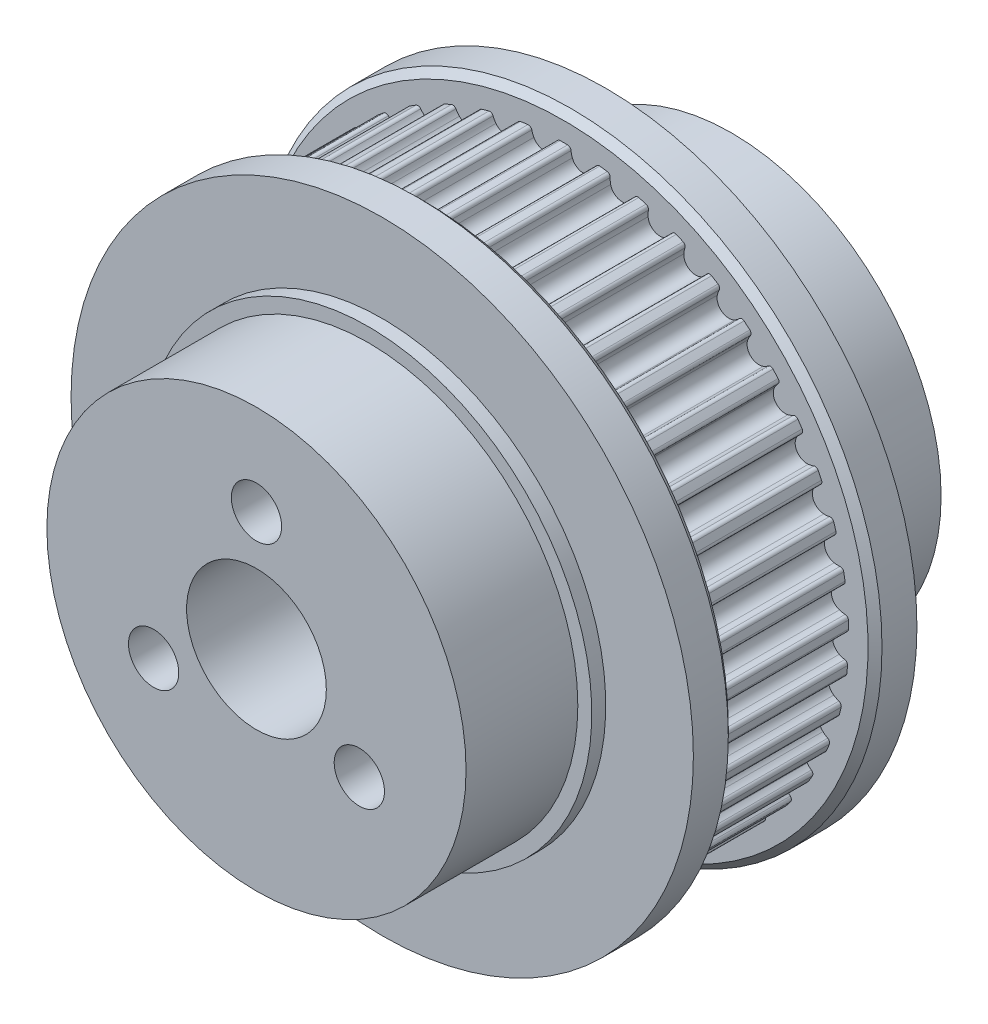
from build123d import *

# Parameters (mm, degrees)
SKETCH_1_R                       = 20.769720073
EXTRUDE_1_DEPTH                  = 5
CUT_EXTRUDE_1_DEPTH              = 32.028415104
PATTERN_CIRCULAR_1_COUNT         = 45
PATTERN_CIRCULAR_1_COPY_1_DEPTH  = 32.028415104
PATTERN_CIRCULAR_1_COPY_2_DEPTH  = 32.028415104
PATTERN_CIRCULAR_1_COPY_3_DEPTH  = 32.028415104
PATTERN_CIRCULAR_1_COPY_4_DEPTH  = 32.028415104
PATTERN_CIRCULAR_1_COPY_5_DEPTH  = 32.028415104
PATTERN_CIRCULAR_1_COPY_6_DEPTH  = 32.028415104
PATTERN_CIRCULAR_1_COPY_7_DEPTH  = 32.028415104
PATTERN_CIRCULAR_1_COPY_8_DEPTH  = 32.028415104
PATTERN_CIRCULAR_1_COPY_9_DEPTH  = 32.028415104
PATTERN_CIRCULAR_1_COPY_10_DEPTH = 32.028415104
PATTERN_CIRCULAR_1_COPY_11_DEPTH = 32.028415104
PATTERN_CIRCULAR_1_COPY_12_DEPTH = 32.028415104
PATTERN_CIRCULAR_1_COPY_13_DEPTH = 32.028415104
PATTERN_CIRCULAR_1_COPY_14_DEPTH = 32.028415104
PATTERN_CIRCULAR_1_COPY_15_DEPTH = 32.028415104
PATTERN_CIRCULAR_1_COPY_16_DEPTH = 32.028415104
PATTERN_CIRCULAR_1_COPY_17_DEPTH = 32.028415104
PATTERN_CIRCULAR_1_COPY_18_DEPTH = 32.028415104
PATTERN_CIRCULAR_1_COPY_19_DEPTH = 32.028415104
PATTERN_CIRCULAR_1_COPY_20_DEPTH = 32.028415104
PATTERN_CIRCULAR_1_COPY_21_DEPTH = 32.028415104
PATTERN_CIRCULAR_1_COPY_22_DEPTH = 32.028415104
PATTERN_CIRCULAR_1_COPY_23_DEPTH = 32.028415104
PATTERN_CIRCULAR_1_COPY_24_DEPTH = 32.028415104
PATTERN_CIRCULAR_1_COPY_25_DEPTH = 32.028415104
PATTERN_CIRCULAR_1_COPY_26_DEPTH = 32.028415104
PATTERN_CIRCULAR_1_COPY_27_DEPTH = 32.028415104
PATTERN_CIRCULAR_1_COPY_28_DEPTH = 32.028415104
PATTERN_CIRCULAR_1_COPY_29_DEPTH = 32.028415104
PATTERN_CIRCULAR_1_COPY_30_DEPTH = 32.028415104
PATTERN_CIRCULAR_1_COPY_31_DEPTH = 32.028415104
PATTERN_CIRCULAR_1_COPY_32_DEPTH = 32.028415104
PATTERN_CIRCULAR_1_COPY_33_DEPTH = 32.028415104
PATTERN_CIRCULAR_1_COPY_34_DEPTH = 32.028415104
PATTERN_CIRCULAR_1_COPY_35_DEPTH = 32.028415104
PATTERN_CIRCULAR_1_COPY_36_DEPTH = 32.028415104
PATTERN_CIRCULAR_1_COPY_37_DEPTH = 32.028415104
PATTERN_CIRCULAR_1_COPY_38_DEPTH = 32.028415104
PATTERN_CIRCULAR_1_COPY_39_DEPTH = 32.028415104
PATTERN_CIRCULAR_1_COPY_40_DEPTH = 32.028415104
PATTERN_CIRCULAR_1_COPY_41_DEPTH = 32.028415104
PATTERN_CIRCULAR_1_COPY_42_DEPTH = 32.028415104
PATTERN_CIRCULAR_1_COPY_43_DEPTH = 32.028415104
PATTERN_CIRCULAR_1_COPY_44_DEPTH = 32.028415104
SKETCH_3_R                       = 22.269720073
EXTRUDE_2_DEPTH                  = 3
CHAMFER_1_SIZE                   = 0.5
SKETCH_7_R                       = 22.269720073
EXTRUDE_3_DEPTH                  = 3
CHAMFER_2_SIZE                   = 0.5
SKETCH_12_R                      = 15
EXTRUDE_4_DEPTH                  = 9
SKETCH_16_R                      = 16
SKETCH_16_R_2                    = 15
EXTRUDE_7_DEPTH                  = 1
SKETCH_4_R                       = 5
CUT_EXTRUDE_4_DEPTH              = 36.789395976
CUT_EXTRUDE_4_DEPTH_BACK         = 36.789395976
HOLE_WIZARD_M3_1_D               = 3.6
HOLE_WIZARD_M3_1_CBORE_D         = 6.5
HOLE_WIZARD_M3_1_CBORE_DEPTH     = 13
PATTERN_CIRCULAR_2_COUNT         = 3


with BuildPart() as part:
    # ｽｹｯﾁ1 → ﾎﾞｽ - 押し出し1 (new, symmetric)
    with BuildSketch(Plane.XY):
        Circle(SKETCH_1_R)
    extrude(amount=EXTRUDE_1_DEPTH, both=True)

    # ｽｹｯﾁ2 → ｶｯﾄ - 押し出し1 (cut, through all)
    with BuildSketch(Plane.XY.offset(5)):
        with BuildLine():
            Line((0, 20.769720073), (0, 20.388720073))
            ThreePointArc((0, 20.388720073), (0.134629216, 20.388275582), (0.269252561, 20.386942127))
            ThreePointArc((0.269252561, 20.386942127), (0.436454679, 20.319798607), (0.515090947, 20.157684024))
            ThreePointArc((0.515090947, 20.157684024), (0.546429865, 19.952254747), (0.605495363, 19.753019753))
            ThreePointArc((0.605495363, 19.753019753), (0.89304001, 19.368993677), (1.342722836, 19.201831159))
            Line((1.342722836, 19.201831159), (1.448822433, 20.719126079))
            ThreePointArc((1.448822433, 20.719126079), (0.724852777, 20.757067721), (0, 20.769720073))
        make_face()
    cut_extrude_1 = extrude(amount=-CUT_EXTRUDE_1_DEPTH, mode=Mode.SUBTRACT)

    # ﾐﾗｰ1: ｶｯﾄ - 押し出し1 across plane
    add(cut_extrude_1.mirror(Plane(origin=(0, 0, 0), x_dir=(0, 0, 1), z_dir=(1, 0, 0))), mode=Mode.SUBTRACT)

    # 円形ﾊﾟﾀｰﾝ1: ｶｯﾄ - 押し出し1 ×45 about axis
    pattern_circular_1_axis = Axis((0, 0, 0), (0, 0, 1))
    for i in range(1, PATTERN_CIRCULAR_1_COUNT):
        add(cut_extrude_1.rotate(pattern_circular_1_axis, i * 360 / PATTERN_CIRCULAR_1_COUNT), mode=Mode.SUBTRACT)

    # 円形ﾊﾟﾀｰﾝ1 copy 1 sketch → 円形ﾊﾟﾀｰﾝ1 copy 1 (cut, through all)
    with BuildSketch(Plane(origin=(0, 0, 5), x_dir=(-0.9902680687415704, -0.13917310096006544, 0), z_dir=(0, 0, 1))):
        with BuildLine():
            Line((0, -20.769720073), (0, -20.388720073))
            ThreePointArc((0, -20.388720073), (0.134629216, -20.388275582), (0.269252561, -20.386942127))
            ThreePointArc((0.269252561, -20.386942127), (0.436454679, -20.319798607), (0.515090947, -20.157684024))
            ThreePointArc((0.515090947, -20.157684024), (0.546429865, -19.952254747), (0.605495363, -19.753019753))
            ThreePointArc((0.605495363, -19.753019753), (0.89304001, -19.368993677), (1.342722836, -19.201831159))
            Line((1.342722836, -19.201831159), (1.448822433, -20.719126079))
            ThreePointArc((1.448822433, -20.719126079), (0.724852777, -20.757067721), (0, -20.769720073))
        make_face()
    extrude(amount=-PATTERN_CIRCULAR_1_COPY_1_DEPTH, mode=Mode.SUBTRACT)

    # 円形ﾊﾟﾀｰﾝ1 copy 2 sketch → 円形ﾊﾟﾀｰﾝ1 copy 2 (cut, through all)
    with BuildSketch(Plane(origin=(0, 0, 5), x_dir=(-0.9612616959383189, -0.27563735581699916, 0), z_dir=(0, 0, 1))):
        with BuildLine():
            Line((0, -20.769720073), (0, -20.388720073))
            ThreePointArc((0, -20.388720073), (0.134629216, -20.388275582), (0.269252561, -20.386942127))
            ThreePointArc((0.269252561, -20.386942127), (0.436454679, -20.319798607), (0.515090947, -20.157684024))
            ThreePointArc((0.515090947, -20.157684024), (0.546429865, -19.952254747), (0.605495363, -19.753019753))
            ThreePointArc((0.605495363, -19.753019753), (0.89304001, -19.368993677), (1.342722836, -19.201831159))
            Line((1.342722836, -19.201831159), (1.448822433, -20.719126079))
            ThreePointArc((1.448822433, -20.719126079), (0.724852777, -20.757067721), (0, -20.769720073))
        make_face()
    extrude(amount=-PATTERN_CIRCULAR_1_COPY_2_DEPTH, mode=Mode.SUBTRACT)

    # 円形ﾊﾟﾀｰﾝ1 copy 3 sketch → 円形ﾊﾟﾀｰﾝ1 copy 3 (cut, through all)
    with BuildSketch(Plane(origin=(0, 0, 5), x_dir=(-0.9135454576426009, -0.4067366430758002, 0), z_dir=(0, 0, 1))):
        with BuildLine():
            Line((0, -20.769720073), (0, -20.388720073))
            ThreePointArc((0, -20.388720073), (0.134629216, -20.388275582), (0.269252561, -20.386942127))
            ThreePointArc((0.269252561, -20.386942127), (0.436454679, -20.319798607), (0.515090947, -20.157684024))
            ThreePointArc((0.515090947, -20.157684024), (0.546429865, -19.952254747), (0.605495363, -19.753019753))
            ThreePointArc((0.605495363, -19.753019753), (0.89304001, -19.368993677), (1.342722836, -19.201831159))
            Line((1.342722836, -19.201831159), (1.448822433, -20.719126079))
            ThreePointArc((1.448822433, -20.719126079), (0.724852777, -20.757067721), (0, -20.769720073))
        make_face()
    extrude(amount=-PATTERN_CIRCULAR_1_COPY_3_DEPTH, mode=Mode.SUBTRACT)

    # 円形ﾊﾟﾀｰﾝ1 copy 4 sketch → 円形ﾊﾟﾀｰﾝ1 copy 4 (cut, through all)
    with BuildSketch(Plane(origin=(0, 0, 5), x_dir=(-0.848048096156426, -0.5299192642332049, 0), z_dir=(0, 0, 1))):
        with BuildLine():
            Line((0, -20.769720073), (0, -20.388720073))
            ThreePointArc((0, -20.388720073), (0.134629216, -20.388275582), (0.269252561, -20.386942127))
            ThreePointArc((0.269252561, -20.386942127), (0.436454679, -20.319798607), (0.515090947, -20.157684024))
            ThreePointArc((0.515090947, -20.157684024), (0.546429865, -19.952254747), (0.605495363, -19.753019753))
            ThreePointArc((0.605495363, -19.753019753), (0.89304001, -19.368993677), (1.342722836, -19.201831159))
            Line((1.342722836, -19.201831159), (1.448822433, -20.719126079))
            ThreePointArc((1.448822433, -20.719126079), (0.724852777, -20.757067721), (0, -20.769720073))
        make_face()
    extrude(amount=-PATTERN_CIRCULAR_1_COPY_4_DEPTH, mode=Mode.SUBTRACT)

    # 円形ﾊﾟﾀｰﾝ1 copy 5 sketch → 円形ﾊﾟﾀｰﾝ1 copy 5 (cut, through all)
    with BuildSketch(Plane(origin=(0, 0, 5), x_dir=(-0.766044443118978, -0.6427876096865393, 0), z_dir=(0, 0, 1))):
        with BuildLine():
            Line((0, -20.769720073), (0, -20.388720073))
            ThreePointArc((0, -20.388720073), (0.134629216, -20.388275582), (0.269252561, -20.386942127))
            ThreePointArc((0.269252561, -20.386942127), (0.436454679, -20.319798607), (0.515090947, -20.157684024))
            ThreePointArc((0.515090947, -20.157684024), (0.546429865, -19.952254747), (0.605495363, -19.753019753))
            ThreePointArc((0.605495363, -19.753019753), (0.89304001, -19.368993677), (1.342722836, -19.201831159))
            Line((1.342722836, -19.201831159), (1.448822433, -20.719126079))
            ThreePointArc((1.448822433, -20.719126079), (0.724852777, -20.757067721), (0, -20.769720073))
        make_face()
    extrude(amount=-PATTERN_CIRCULAR_1_COPY_5_DEPTH, mode=Mode.SUBTRACT)

    # 円形ﾊﾟﾀｰﾝ1 copy 6 sketch → 円形ﾊﾟﾀｰﾝ1 copy 6 (cut, through all)
    with BuildSketch(Plane(origin=(0, 0, 5), x_dir=(-0.6691306063588582, -0.7431448254773942, 0), z_dir=(0, 0, 1))):
        with BuildLine():
            Line((0, -20.769720073), (0, -20.388720073))
            ThreePointArc((0, -20.388720073), (0.134629216, -20.388275582), (0.269252561, -20.386942127))
            ThreePointArc((0.269252561, -20.386942127), (0.436454679, -20.319798607), (0.515090947, -20.157684024))
            ThreePointArc((0.515090947, -20.157684024), (0.546429865, -19.952254747), (0.605495363, -19.753019753))
            ThreePointArc((0.605495363, -19.753019753), (0.89304001, -19.368993677), (1.342722836, -19.201831159))
            Line((1.342722836, -19.201831159), (1.448822433, -20.719126079))
            ThreePointArc((1.448822433, -20.719126079), (0.724852777, -20.757067721), (0, -20.769720073))
        make_face()
    extrude(amount=-PATTERN_CIRCULAR_1_COPY_6_DEPTH, mode=Mode.SUBTRACT)

    # 円形ﾊﾟﾀｰﾝ1 copy 7 sketch → 円形ﾊﾟﾀｰﾝ1 copy 7 (cut, through all)
    with BuildSketch(Plane(origin=(0, 0, 5), x_dir=(-0.5591929034707468, -0.8290375725550417, 0), z_dir=(0, 0, 1))):
        with BuildLine():
            Line((0, -20.769720073), (0, -20.388720073))
            ThreePointArc((0, -20.388720073), (0.134629216, -20.388275582), (0.269252561, -20.386942127))
            ThreePointArc((0.269252561, -20.386942127), (0.436454679, -20.319798607), (0.515090947, -20.157684024))
            ThreePointArc((0.515090947, -20.157684024), (0.546429865, -19.952254747), (0.605495363, -19.753019753))
            ThreePointArc((0.605495363, -19.753019753), (0.89304001, -19.368993677), (1.342722836, -19.201831159))
            Line((1.342722836, -19.201831159), (1.448822433, -20.719126079))
            ThreePointArc((1.448822433, -20.719126079), (0.724852777, -20.757067721), (0, -20.769720073))
        make_face()
    extrude(amount=-PATTERN_CIRCULAR_1_COPY_7_DEPTH, mode=Mode.SUBTRACT)

    # 円形ﾊﾟﾀｰﾝ1 copy 8 sketch → 円形ﾊﾟﾀｰﾝ1 copy 8 (cut, through all)
    with BuildSketch(Plane(origin=(0, 0, 5), x_dir=(-0.43837114678907746, -0.898794046299167, 0), z_dir=(0, 0, 1))):
        with BuildLine():
            Line((0, -20.769720073), (0, -20.388720073))
            ThreePointArc((0, -20.388720073), (0.134629216, -20.388275582), (0.269252561, -20.386942127))
            ThreePointArc((0.269252561, -20.386942127), (0.436454679, -20.319798607), (0.515090947, -20.157684024))
            ThreePointArc((0.515090947, -20.157684024), (0.546429865, -19.952254747), (0.605495363, -19.753019753))
            ThreePointArc((0.605495363, -19.753019753), (0.89304001, -19.368993677), (1.342722836, -19.201831159))
            Line((1.342722836, -19.201831159), (1.448822433, -20.719126079))
            ThreePointArc((1.448822433, -20.719126079), (0.724852777, -20.757067721), (0, -20.769720073))
        make_face()
    extrude(amount=-PATTERN_CIRCULAR_1_COPY_8_DEPTH, mode=Mode.SUBTRACT)

    # 円形ﾊﾟﾀｰﾝ1 copy 9 sketch → 円形ﾊﾟﾀｰﾝ1 copy 9 (cut, through all)
    with BuildSketch(Plane(origin=(0, 0, 5), x_dir=(-0.30901699437494745, -0.9510565162951535, 0), z_dir=(0, 0, 1))):
        with BuildLine():
            Line((0, -20.769720073), (0, -20.388720073))
            ThreePointArc((0, -20.388720073), (0.134629216, -20.388275582), (0.269252561, -20.386942127))
            ThreePointArc((0.269252561, -20.386942127), (0.436454679, -20.319798607), (0.515090947, -20.157684024))
            ThreePointArc((0.515090947, -20.157684024), (0.546429865, -19.952254747), (0.605495363, -19.753019753))
            ThreePointArc((0.605495363, -19.753019753), (0.89304001, -19.368993677), (1.342722836, -19.201831159))
            Line((1.342722836, -19.201831159), (1.448822433, -20.719126079))
            ThreePointArc((1.448822433, -20.719126079), (0.724852777, -20.757067721), (0, -20.769720073))
        make_face()
    extrude(amount=-PATTERN_CIRCULAR_1_COPY_9_DEPTH, mode=Mode.SUBTRACT)

    # 円形ﾊﾟﾀｰﾝ1 copy 10 sketch → 円形ﾊﾟﾀｰﾝ1 copy 10 (cut, through all)
    with BuildSketch(Plane(origin=(0, 0, 5), x_dir=(-0.17364817766693041, -0.984807753012208, 0), z_dir=(0, 0, 1))):
        with BuildLine():
            Line((0, -20.769720073), (0, -20.388720073))
            ThreePointArc((0, -20.388720073), (0.134629216, -20.388275582), (0.269252561, -20.386942127))
            ThreePointArc((0.269252561, -20.386942127), (0.436454679, -20.319798607), (0.515090947, -20.157684024))
            ThreePointArc((0.515090947, -20.157684024), (0.546429865, -19.952254747), (0.605495363, -19.753019753))
            ThreePointArc((0.605495363, -19.753019753), (0.89304001, -19.368993677), (1.342722836, -19.201831159))
            Line((1.342722836, -19.201831159), (1.448822433, -20.719126079))
            ThreePointArc((1.448822433, -20.719126079), (0.724852777, -20.757067721), (0, -20.769720073))
        make_face()
    extrude(amount=-PATTERN_CIRCULAR_1_COPY_10_DEPTH, mode=Mode.SUBTRACT)

    # 円形ﾊﾟﾀｰﾝ1 copy 11 sketch → 円形ﾊﾟﾀｰﾝ1 copy 11 (cut, through all)
    with BuildSketch(Plane(origin=(0, 0, 5), x_dir=(-0.03489949670250108, -0.9993908270190958, 0), z_dir=(0, 0, 1))):
        with BuildLine():
            Line((0, -20.769720073), (0, -20.388720073))
            ThreePointArc((0, -20.388720073), (0.134629216, -20.388275582), (0.269252561, -20.386942127))
            ThreePointArc((0.269252561, -20.386942127), (0.436454679, -20.319798607), (0.515090947, -20.157684024))
            ThreePointArc((0.515090947, -20.157684024), (0.546429865, -19.952254747), (0.605495363, -19.753019753))
            ThreePointArc((0.605495363, -19.753019753), (0.89304001, -19.368993677), (1.342722836, -19.201831159))
            Line((1.342722836, -19.201831159), (1.448822433, -20.719126079))
            ThreePointArc((1.448822433, -20.719126079), (0.724852777, -20.757067721), (0, -20.769720073))
        make_face()
    extrude(amount=-PATTERN_CIRCULAR_1_COPY_11_DEPTH, mode=Mode.SUBTRACT)

    # 円形ﾊﾟﾀｰﾝ1 copy 12 sketch → 円形ﾊﾟﾀｰﾝ1 copy 12 (cut, through all)
    with BuildSketch(Plane(origin=(0, 0, 5), x_dir=(0.10452846326765355, -0.9945218953682733, 0), z_dir=(0, 0, 1))):
        with BuildLine():
            Line((0, -20.769720073), (0, -20.388720073))
            ThreePointArc((0, -20.388720073), (0.134629216, -20.388275582), (0.269252561, -20.386942127))
            ThreePointArc((0.269252561, -20.386942127), (0.436454679, -20.319798607), (0.515090947, -20.157684024))
            ThreePointArc((0.515090947, -20.157684024), (0.546429865, -19.952254747), (0.605495363, -19.753019753))
            ThreePointArc((0.605495363, -19.753019753), (0.89304001, -19.368993677), (1.342722836, -19.201831159))
            Line((1.342722836, -19.201831159), (1.448822433, -20.719126079))
            ThreePointArc((1.448822433, -20.719126079), (0.724852777, -20.757067721), (0, -20.769720073))
        make_face()
    extrude(amount=-PATTERN_CIRCULAR_1_COPY_12_DEPTH, mode=Mode.SUBTRACT)

    # 円形ﾊﾟﾀｰﾝ1 copy 13 sketch → 円形ﾊﾟﾀｰﾝ1 copy 13 (cut, through all)
    with BuildSketch(Plane(origin=(0, 0, 5), x_dir=(0.24192189559966779, -0.9702957262759965, 0), z_dir=(0, 0, 1))):
        with BuildLine():
            Line((0, -20.769720073), (0, -20.388720073))
            ThreePointArc((0, -20.388720073), (0.134629216, -20.388275582), (0.269252561, -20.386942127))
            ThreePointArc((0.269252561, -20.386942127), (0.436454679, -20.319798607), (0.515090947, -20.157684024))
            ThreePointArc((0.515090947, -20.157684024), (0.546429865, -19.952254747), (0.605495363, -19.753019753))
            ThreePointArc((0.605495363, -19.753019753), (0.89304001, -19.368993677), (1.342722836, -19.201831159))
            Line((1.342722836, -19.201831159), (1.448822433, -20.719126079))
            ThreePointArc((1.448822433, -20.719126079), (0.724852777, -20.757067721), (0, -20.769720073))
        make_face()
    extrude(amount=-PATTERN_CIRCULAR_1_COPY_13_DEPTH, mode=Mode.SUBTRACT)

    # 円形ﾊﾟﾀｰﾝ1 copy 14 sketch → 円形ﾊﾟﾀｰﾝ1 copy 14 (cut, through all)
    with BuildSketch(Plane(origin=(0, 0, 5), x_dir=(0.37460659341591207, -0.9271838545667874, 0), z_dir=(0, 0, 1))):
        with BuildLine():
            Line((0, -20.769720073), (0, -20.388720073))
            ThreePointArc((0, -20.388720073), (0.134629216, -20.388275582), (0.269252561, -20.386942127))
            ThreePointArc((0.269252561, -20.386942127), (0.436454679, -20.319798607), (0.515090947, -20.157684024))
            ThreePointArc((0.515090947, -20.157684024), (0.546429865, -19.952254747), (0.605495363, -19.753019753))
            ThreePointArc((0.605495363, -19.753019753), (0.89304001, -19.368993677), (1.342722836, -19.201831159))
            Line((1.342722836, -19.201831159), (1.448822433, -20.719126079))
            ThreePointArc((1.448822433, -20.719126079), (0.724852777, -20.757067721), (0, -20.769720073))
        make_face()
    extrude(amount=-PATTERN_CIRCULAR_1_COPY_14_DEPTH, mode=Mode.SUBTRACT)

    # 円形ﾊﾟﾀｰﾝ1 copy 15 sketch → 円形ﾊﾟﾀｰﾝ1 copy 15 (cut, through all)
    with BuildSketch(Plane(origin=(0, 0, 5), x_dir=(0.4999999999999998, -0.8660254037844387, 0), z_dir=(0, 0, 1))):
        with BuildLine():
            Line((0, -20.769720073), (0, -20.388720073))
            ThreePointArc((0, -20.388720073), (0.134629216, -20.388275582), (0.269252561, -20.386942127))
            ThreePointArc((0.269252561, -20.386942127), (0.436454679, -20.319798607), (0.515090947, -20.157684024))
            ThreePointArc((0.515090947, -20.157684024), (0.546429865, -19.952254747), (0.605495363, -19.753019753))
            ThreePointArc((0.605495363, -19.753019753), (0.89304001, -19.368993677), (1.342722836, -19.201831159))
            Line((1.342722836, -19.201831159), (1.448822433, -20.719126079))
            ThreePointArc((1.448822433, -20.719126079), (0.724852777, -20.757067721), (0, -20.769720073))
        make_face()
    extrude(amount=-PATTERN_CIRCULAR_1_COPY_15_DEPTH, mode=Mode.SUBTRACT)

    # 円形ﾊﾟﾀｰﾝ1 copy 16 sketch → 円形ﾊﾟﾀｰﾝ1 copy 16 (cut, through all)
    with BuildSketch(Plane(origin=(0, 0, 5), x_dir=(0.6156614753256583, -0.788010753606722, 0), z_dir=(0, 0, 1))):
        with BuildLine():
            Line((0, -20.769720073), (0, -20.388720073))
            ThreePointArc((0, -20.388720073), (0.134629216, -20.388275582), (0.269252561, -20.386942127))
            ThreePointArc((0.269252561, -20.386942127), (0.436454679, -20.319798607), (0.515090947, -20.157684024))
            ThreePointArc((0.515090947, -20.157684024), (0.546429865, -19.952254747), (0.605495363, -19.753019753))
            ThreePointArc((0.605495363, -19.753019753), (0.89304001, -19.368993677), (1.342722836, -19.201831159))
            Line((1.342722836, -19.201831159), (1.448822433, -20.719126079))
            ThreePointArc((1.448822433, -20.719126079), (0.724852777, -20.757067721), (0, -20.769720073))
        make_face()
    extrude(amount=-PATTERN_CIRCULAR_1_COPY_16_DEPTH, mode=Mode.SUBTRACT)

    # 円形ﾊﾟﾀｰﾝ1 copy 17 sketch → 円形ﾊﾟﾀｰﾝ1 copy 17 (cut, through all)
    with BuildSketch(Plane(origin=(0, 0, 5), x_dir=(0.7193398003386512, -0.6946583704589971, 0), z_dir=(0, 0, 1))):
        with BuildLine():
            Line((0, -20.769720073), (0, -20.388720073))
            ThreePointArc((0, -20.388720073), (0.134629216, -20.388275582), (0.269252561, -20.386942127))
            ThreePointArc((0.269252561, -20.386942127), (0.436454679, -20.319798607), (0.515090947, -20.157684024))
            ThreePointArc((0.515090947, -20.157684024), (0.546429865, -19.952254747), (0.605495363, -19.753019753))
            ThreePointArc((0.605495363, -19.753019753), (0.89304001, -19.368993677), (1.342722836, -19.201831159))
            Line((1.342722836, -19.201831159), (1.448822433, -20.719126079))
            ThreePointArc((1.448822433, -20.719126079), (0.724852777, -20.757067721), (0, -20.769720073))
        make_face()
    extrude(amount=-PATTERN_CIRCULAR_1_COPY_17_DEPTH, mode=Mode.SUBTRACT)

    # 円形ﾊﾟﾀｰﾝ1 copy 18 sketch → 円形ﾊﾟﾀｰﾝ1 copy 18 (cut, through all)
    with BuildSketch(Plane(origin=(0, 0, 5), x_dir=(0.8090169943749473, -0.5877852522924732, 0), z_dir=(0, 0, 1))):
        with BuildLine():
            Line((0, -20.769720073), (0, -20.388720073))
            ThreePointArc((0, -20.388720073), (0.134629216, -20.388275582), (0.269252561, -20.386942127))
            ThreePointArc((0.269252561, -20.386942127), (0.436454679, -20.319798607), (0.515090947, -20.157684024))
            ThreePointArc((0.515090947, -20.157684024), (0.546429865, -19.952254747), (0.605495363, -19.753019753))
            ThreePointArc((0.605495363, -19.753019753), (0.89304001, -19.368993677), (1.342722836, -19.201831159))
            Line((1.342722836, -19.201831159), (1.448822433, -20.719126079))
            ThreePointArc((1.448822433, -20.719126079), (0.724852777, -20.757067721), (0, -20.769720073))
        make_face()
    extrude(amount=-PATTERN_CIRCULAR_1_COPY_18_DEPTH, mode=Mode.SUBTRACT)

    # 円形ﾊﾟﾀｰﾝ1 copy 19 sketch → 円形ﾊﾟﾀｰﾝ1 copy 19 (cut, through all)
    with BuildSketch(Plane(origin=(0, 0, 5), x_dir=(0.882947592858927, -0.4694715627858907, 0), z_dir=(0, 0, 1))):
        with BuildLine():
            Line((0, -20.769720073), (0, -20.388720073))
            ThreePointArc((0, -20.388720073), (0.134629216, -20.388275582), (0.269252561, -20.386942127))
            ThreePointArc((0.269252561, -20.386942127), (0.436454679, -20.319798607), (0.515090947, -20.157684024))
            ThreePointArc((0.515090947, -20.157684024), (0.546429865, -19.952254747), (0.605495363, -19.753019753))
            ThreePointArc((0.605495363, -19.753019753), (0.89304001, -19.368993677), (1.342722836, -19.201831159))
            Line((1.342722836, -19.201831159), (1.448822433, -20.719126079))
            ThreePointArc((1.448822433, -20.719126079), (0.724852777, -20.757067721), (0, -20.769720073))
        make_face()
    extrude(amount=-PATTERN_CIRCULAR_1_COPY_19_DEPTH, mode=Mode.SUBTRACT)

    # 円形ﾊﾟﾀｰﾝ1 copy 20 sketch → 円形ﾊﾟﾀｰﾝ1 copy 20 (cut, through all)
    with BuildSketch(Plane(origin=(0, 0, 5), x_dir=(0.9396926207859083, -0.3420201433256689, 0), z_dir=(0, 0, 1))):
        with BuildLine():
            Line((0, -20.769720073), (0, -20.388720073))
            ThreePointArc((0, -20.388720073), (0.134629216, -20.388275582), (0.269252561, -20.386942127))
            ThreePointArc((0.269252561, -20.386942127), (0.436454679, -20.319798607), (0.515090947, -20.157684024))
            ThreePointArc((0.515090947, -20.157684024), (0.546429865, -19.952254747), (0.605495363, -19.753019753))
            ThreePointArc((0.605495363, -19.753019753), (0.89304001, -19.368993677), (1.342722836, -19.201831159))
            Line((1.342722836, -19.201831159), (1.448822433, -20.719126079))
            ThreePointArc((1.448822433, -20.719126079), (0.724852777, -20.757067721), (0, -20.769720073))
        make_face()
    extrude(amount=-PATTERN_CIRCULAR_1_COPY_20_DEPTH, mode=Mode.SUBTRACT)

    # 円形ﾊﾟﾀｰﾝ1 copy 21 sketch → 円形ﾊﾟﾀｰﾝ1 copy 21 (cut, through all)
    with BuildSketch(Plane(origin=(0, 0, 5), x_dir=(0.9781476007338057, -0.20791169081775931, 0), z_dir=(0, 0, 1))):
        with BuildLine():
            Line((0, -20.769720073), (0, -20.388720073))
            ThreePointArc((0, -20.388720073), (0.134629216, -20.388275582), (0.269252561, -20.386942127))
            ThreePointArc((0.269252561, -20.386942127), (0.436454679, -20.319798607), (0.515090947, -20.157684024))
            ThreePointArc((0.515090947, -20.157684024), (0.546429865, -19.952254747), (0.605495363, -19.753019753))
            ThreePointArc((0.605495363, -19.753019753), (0.89304001, -19.368993677), (1.342722836, -19.201831159))
            Line((1.342722836, -19.201831159), (1.448822433, -20.719126079))
            ThreePointArc((1.448822433, -20.719126079), (0.724852777, -20.757067721), (0, -20.769720073))
        make_face()
    extrude(amount=-PATTERN_CIRCULAR_1_COPY_21_DEPTH, mode=Mode.SUBTRACT)

    # 円形ﾊﾟﾀｰﾝ1 copy 22 sketch → 円形ﾊﾟﾀｰﾝ1 copy 22 (cut, through all)
    with BuildSketch(Plane(origin=(0, 0, 5), x_dir=(0.9975640502598242, -0.06975647374412552, 0), z_dir=(0, 0, 1))):
        with BuildLine():
            Line((0, -20.769720073), (0, -20.388720073))
            ThreePointArc((0, -20.388720073), (0.134629216, -20.388275582), (0.269252561, -20.386942127))
            ThreePointArc((0.269252561, -20.386942127), (0.436454679, -20.319798607), (0.515090947, -20.157684024))
            ThreePointArc((0.515090947, -20.157684024), (0.546429865, -19.952254747), (0.605495363, -19.753019753))
            ThreePointArc((0.605495363, -19.753019753), (0.89304001, -19.368993677), (1.342722836, -19.201831159))
            Line((1.342722836, -19.201831159), (1.448822433, -20.719126079))
            ThreePointArc((1.448822433, -20.719126079), (0.724852777, -20.757067721), (0, -20.769720073))
        make_face()
    extrude(amount=-PATTERN_CIRCULAR_1_COPY_22_DEPTH, mode=Mode.SUBTRACT)

    # 円形ﾊﾟﾀｰﾝ1 copy 23 sketch → 円形ﾊﾟﾀｰﾝ1 copy 23 (cut, through all)
    with BuildSketch(Plane(origin=(0, 0, 5), x_dir=(0.9975640502598242, 0.06975647374412527, 0), z_dir=(0, 0, 1))):
        with BuildLine():
            Line((0, -20.769720073), (0, -20.388720073))
            ThreePointArc((0, -20.388720073), (0.134629216, -20.388275582), (0.269252561, -20.386942127))
            ThreePointArc((0.269252561, -20.386942127), (0.436454679, -20.319798607), (0.515090947, -20.157684024))
            ThreePointArc((0.515090947, -20.157684024), (0.546429865, -19.952254747), (0.605495363, -19.753019753))
            ThreePointArc((0.605495363, -19.753019753), (0.89304001, -19.368993677), (1.342722836, -19.201831159))
            Line((1.342722836, -19.201831159), (1.448822433, -20.719126079))
            ThreePointArc((1.448822433, -20.719126079), (0.724852777, -20.757067721), (0, -20.769720073))
        make_face()
    extrude(amount=-PATTERN_CIRCULAR_1_COPY_23_DEPTH, mode=Mode.SUBTRACT)

    # 円形ﾊﾟﾀｰﾝ1 copy 24 sketch → 円形ﾊﾟﾀｰﾝ1 copy 24 (cut, through all)
    with BuildSketch(Plane(origin=(0, 0, 5), x_dir=(0.9781476007338056, 0.2079116908177595, 0), z_dir=(0, 0, 1))):
        with BuildLine():
            Line((0, -20.769720073), (0, -20.388720073))
            ThreePointArc((0, -20.388720073), (0.134629216, -20.388275582), (0.269252561, -20.386942127))
            ThreePointArc((0.269252561, -20.386942127), (0.436454679, -20.319798607), (0.515090947, -20.157684024))
            ThreePointArc((0.515090947, -20.157684024), (0.546429865, -19.952254747), (0.605495363, -19.753019753))
            ThreePointArc((0.605495363, -19.753019753), (0.89304001, -19.368993677), (1.342722836, -19.201831159))
            Line((1.342722836, -19.201831159), (1.448822433, -20.719126079))
            ThreePointArc((1.448822433, -20.719126079), (0.724852777, -20.757067721), (0, -20.769720073))
        make_face()
    extrude(amount=-PATTERN_CIRCULAR_1_COPY_24_DEPTH, mode=Mode.SUBTRACT)

    # 円形ﾊﾟﾀｰﾝ1 copy 25 sketch → 円形ﾊﾟﾀｰﾝ1 copy 25 (cut, through all)
    with BuildSketch(Plane(origin=(0, 0, 5), x_dir=(0.9396926207859084, 0.34202014332566866, 0), z_dir=(0, 0, 1))):
        with BuildLine():
            Line((0, -20.769720073), (0, -20.388720073))
            ThreePointArc((0, -20.388720073), (0.134629216, -20.388275582), (0.269252561, -20.386942127))
            ThreePointArc((0.269252561, -20.386942127), (0.436454679, -20.319798607), (0.515090947, -20.157684024))
            ThreePointArc((0.515090947, -20.157684024), (0.546429865, -19.952254747), (0.605495363, -19.753019753))
            ThreePointArc((0.605495363, -19.753019753), (0.89304001, -19.368993677), (1.342722836, -19.201831159))
            Line((1.342722836, -19.201831159), (1.448822433, -20.719126079))
            ThreePointArc((1.448822433, -20.719126079), (0.724852777, -20.757067721), (0, -20.769720073))
        make_face()
    extrude(amount=-PATTERN_CIRCULAR_1_COPY_25_DEPTH, mode=Mode.SUBTRACT)

    # 円形ﾊﾟﾀｰﾝ1 copy 26 sketch → 円形ﾊﾟﾀｰﾝ1 copy 26 (cut, through all)
    with BuildSketch(Plane(origin=(0, 0, 5), x_dir=(0.8829475928589269, 0.46947156278589086, 0), z_dir=(0, 0, 1))):
        with BuildLine():
            Line((0, -20.769720073), (0, -20.388720073))
            ThreePointArc((0, -20.388720073), (0.134629216, -20.388275582), (0.269252561, -20.386942127))
            ThreePointArc((0.269252561, -20.386942127), (0.436454679, -20.319798607), (0.515090947, -20.157684024))
            ThreePointArc((0.515090947, -20.157684024), (0.546429865, -19.952254747), (0.605495363, -19.753019753))
            ThreePointArc((0.605495363, -19.753019753), (0.89304001, -19.368993677), (1.342722836, -19.201831159))
            Line((1.342722836, -19.201831159), (1.448822433, -20.719126079))
            ThreePointArc((1.448822433, -20.719126079), (0.724852777, -20.757067721), (0, -20.769720073))
        make_face()
    extrude(amount=-PATTERN_CIRCULAR_1_COPY_26_DEPTH, mode=Mode.SUBTRACT)

    # 円形ﾊﾟﾀｰﾝ1 copy 27 sketch → 円形ﾊﾟﾀｰﾝ1 copy 27 (cut, through all)
    with BuildSketch(Plane(origin=(0, 0, 5), x_dir=(0.8090169943749476, 0.587785252292473, 0), z_dir=(0, 0, 1))):
        with BuildLine():
            Line((0, -20.769720073), (0, -20.388720073))
            ThreePointArc((0, -20.388720073), (0.134629216, -20.388275582), (0.269252561, -20.386942127))
            ThreePointArc((0.269252561, -20.386942127), (0.436454679, -20.319798607), (0.515090947, -20.157684024))
            ThreePointArc((0.515090947, -20.157684024), (0.546429865, -19.952254747), (0.605495363, -19.753019753))
            ThreePointArc((0.605495363, -19.753019753), (0.89304001, -19.368993677), (1.342722836, -19.201831159))
            Line((1.342722836, -19.201831159), (1.448822433, -20.719126079))
            ThreePointArc((1.448822433, -20.719126079), (0.724852777, -20.757067721), (0, -20.769720073))
        make_face()
    extrude(amount=-PATTERN_CIRCULAR_1_COPY_27_DEPTH, mode=Mode.SUBTRACT)

    # 円形ﾊﾟﾀｰﾝ1 copy 28 sketch → 円形ﾊﾟﾀｰﾝ1 copy 28 (cut, through all)
    with BuildSketch(Plane(origin=(0, 0, 5), x_dir=(0.7193398003386511, 0.6946583704589974, 0), z_dir=(0, 0, 1))):
        with BuildLine():
            Line((0, -20.769720073), (0, -20.388720073))
            ThreePointArc((0, -20.388720073), (0.134629216, -20.388275582), (0.269252561, -20.386942127))
            ThreePointArc((0.269252561, -20.386942127), (0.436454679, -20.319798607), (0.515090947, -20.157684024))
            ThreePointArc((0.515090947, -20.157684024), (0.546429865, -19.952254747), (0.605495363, -19.753019753))
            ThreePointArc((0.605495363, -19.753019753), (0.89304001, -19.368993677), (1.342722836, -19.201831159))
            Line((1.342722836, -19.201831159), (1.448822433, -20.719126079))
            ThreePointArc((1.448822433, -20.719126079), (0.724852777, -20.757067721), (0, -20.769720073))
        make_face()
    extrude(amount=-PATTERN_CIRCULAR_1_COPY_28_DEPTH, mode=Mode.SUBTRACT)

    # 円形ﾊﾟﾀｰﾝ1 copy 29 sketch → 円形ﾊﾟﾀｰﾝ1 copy 29 (cut, through all)
    with BuildSketch(Plane(origin=(0, 0, 5), x_dir=(0.6156614753256581, 0.7880107536067221, 0), z_dir=(0, 0, 1))):
        with BuildLine():
            Line((0, -20.769720073), (0, -20.388720073))
            ThreePointArc((0, -20.388720073), (0.134629216, -20.388275582), (0.269252561, -20.386942127))
            ThreePointArc((0.269252561, -20.386942127), (0.436454679, -20.319798607), (0.515090947, -20.157684024))
            ThreePointArc((0.515090947, -20.157684024), (0.546429865, -19.952254747), (0.605495363, -19.753019753))
            ThreePointArc((0.605495363, -19.753019753), (0.89304001, -19.368993677), (1.342722836, -19.201831159))
            Line((1.342722836, -19.201831159), (1.448822433, -20.719126079))
            ThreePointArc((1.448822433, -20.719126079), (0.724852777, -20.757067721), (0, -20.769720073))
        make_face()
    extrude(amount=-PATTERN_CIRCULAR_1_COPY_29_DEPTH, mode=Mode.SUBTRACT)

    # 円形ﾊﾟﾀｰﾝ1 copy 30 sketch → 円形ﾊﾟﾀｰﾝ1 copy 30 (cut, through all)
    with BuildSketch(Plane(origin=(0, 0, 5), x_dir=(0.5000000000000004, 0.8660254037844384, 0), z_dir=(0, 0, 1))):
        with BuildLine():
            Line((0, -20.769720073), (0, -20.388720073))
            ThreePointArc((0, -20.388720073), (0.134629216, -20.388275582), (0.269252561, -20.386942127))
            ThreePointArc((0.269252561, -20.386942127), (0.436454679, -20.319798607), (0.515090947, -20.157684024))
            ThreePointArc((0.515090947, -20.157684024), (0.546429865, -19.952254747), (0.605495363, -19.753019753))
            ThreePointArc((0.605495363, -19.753019753), (0.89304001, -19.368993677), (1.342722836, -19.201831159))
            Line((1.342722836, -19.201831159), (1.448822433, -20.719126079))
            ThreePointArc((1.448822433, -20.719126079), (0.724852777, -20.757067721), (0, -20.769720073))
        make_face()
    extrude(amount=-PATTERN_CIRCULAR_1_COPY_30_DEPTH, mode=Mode.SUBTRACT)

    # 円形ﾊﾟﾀｰﾝ1 copy 31 sketch → 円形ﾊﾟﾀｰﾝ1 copy 31 (cut, through all)
    with BuildSketch(Plane(origin=(0, 0, 5), x_dir=(0.3746065934159123, 0.9271838545667873, 0), z_dir=(0, 0, 1))):
        with BuildLine():
            Line((0, -20.769720073), (0, -20.388720073))
            ThreePointArc((0, -20.388720073), (0.134629216, -20.388275582), (0.269252561, -20.386942127))
            ThreePointArc((0.269252561, -20.386942127), (0.436454679, -20.319798607), (0.515090947, -20.157684024))
            ThreePointArc((0.515090947, -20.157684024), (0.546429865, -19.952254747), (0.605495363, -19.753019753))
            ThreePointArc((0.605495363, -19.753019753), (0.89304001, -19.368993677), (1.342722836, -19.201831159))
            Line((1.342722836, -19.201831159), (1.448822433, -20.719126079))
            ThreePointArc((1.448822433, -20.719126079), (0.724852777, -20.757067721), (0, -20.769720073))
        make_face()
    extrude(amount=-PATTERN_CIRCULAR_1_COPY_31_DEPTH, mode=Mode.SUBTRACT)

    # 円形ﾊﾟﾀｰﾝ1 copy 32 sketch → 円形ﾊﾟﾀｰﾝ1 copy 32 (cut, through all)
    with BuildSketch(Plane(origin=(0, 0, 5), x_dir=(0.24192189559966779, 0.9702957262759965, 0), z_dir=(0, 0, 1))):
        with BuildLine():
            Line((0, -20.769720073), (0, -20.388720073))
            ThreePointArc((0, -20.388720073), (0.134629216, -20.388275582), (0.269252561, -20.386942127))
            ThreePointArc((0.269252561, -20.386942127), (0.436454679, -20.319798607), (0.515090947, -20.157684024))
            ThreePointArc((0.515090947, -20.157684024), (0.546429865, -19.952254747), (0.605495363, -19.753019753))
            ThreePointArc((0.605495363, -19.753019753), (0.89304001, -19.368993677), (1.342722836, -19.201831159))
            Line((1.342722836, -19.201831159), (1.448822433, -20.719126079))
            ThreePointArc((1.448822433, -20.719126079), (0.724852777, -20.757067721), (0, -20.769720073))
        make_face()
    extrude(amount=-PATTERN_CIRCULAR_1_COPY_32_DEPTH, mode=Mode.SUBTRACT)

    # 円形ﾊﾟﾀｰﾝ1 copy 33 sketch → 円形ﾊﾟﾀｰﾝ1 copy 33 (cut, through all)
    with BuildSketch(Plane(origin=(0, 0, 5), x_dir=(0.10452846326765336, 0.9945218953682734, 0), z_dir=(0, 0, 1))):
        with BuildLine():
            Line((0, -20.769720073), (0, -20.388720073))
            ThreePointArc((0, -20.388720073), (0.134629216, -20.388275582), (0.269252561, -20.386942127))
            ThreePointArc((0.269252561, -20.386942127), (0.436454679, -20.319798607), (0.515090947, -20.157684024))
            ThreePointArc((0.515090947, -20.157684024), (0.546429865, -19.952254747), (0.605495363, -19.753019753))
            ThreePointArc((0.605495363, -19.753019753), (0.89304001, -19.368993677), (1.342722836, -19.201831159))
            Line((1.342722836, -19.201831159), (1.448822433, -20.719126079))
            ThreePointArc((1.448822433, -20.719126079), (0.724852777, -20.757067721), (0, -20.769720073))
        make_face()
    extrude(amount=-PATTERN_CIRCULAR_1_COPY_33_DEPTH, mode=Mode.SUBTRACT)

    # 円形ﾊﾟﾀｰﾝ1 copy 34 sketch → 円形ﾊﾟﾀｰﾝ1 copy 34 (cut, through all)
    with BuildSketch(Plane(origin=(0, 0, 5), x_dir=(-0.03489949670250128, 0.9993908270190958, 0), z_dir=(0, 0, 1))):
        with BuildLine():
            Line((0, -20.769720073), (0, -20.388720073))
            ThreePointArc((0, -20.388720073), (0.134629216, -20.388275582), (0.269252561, -20.386942127))
            ThreePointArc((0.269252561, -20.386942127), (0.436454679, -20.319798607), (0.515090947, -20.157684024))
            ThreePointArc((0.515090947, -20.157684024), (0.546429865, -19.952254747), (0.605495363, -19.753019753))
            ThreePointArc((0.605495363, -19.753019753), (0.89304001, -19.368993677), (1.342722836, -19.201831159))
            Line((1.342722836, -19.201831159), (1.448822433, -20.719126079))
            ThreePointArc((1.448822433, -20.719126079), (0.724852777, -20.757067721), (0, -20.769720073))
        make_face()
    extrude(amount=-PATTERN_CIRCULAR_1_COPY_34_DEPTH, mode=Mode.SUBTRACT)

    # 円形ﾊﾟﾀｰﾝ1 copy 35 sketch → 円形ﾊﾟﾀｰﾝ1 copy 35 (cut, through all)
    with BuildSketch(Plane(origin=(0, 0, 5), x_dir=(-0.17364817766692997, 0.9848077530122081, 0), z_dir=(0, 0, 1))):
        with BuildLine():
            Line((0, -20.769720073), (0, -20.388720073))
            ThreePointArc((0, -20.388720073), (0.134629216, -20.388275582), (0.269252561, -20.386942127))
            ThreePointArc((0.269252561, -20.386942127), (0.436454679, -20.319798607), (0.515090947, -20.157684024))
            ThreePointArc((0.515090947, -20.157684024), (0.546429865, -19.952254747), (0.605495363, -19.753019753))
            ThreePointArc((0.605495363, -19.753019753), (0.89304001, -19.368993677), (1.342722836, -19.201831159))
            Line((1.342722836, -19.201831159), (1.448822433, -20.719126079))
            ThreePointArc((1.448822433, -20.719126079), (0.724852777, -20.757067721), (0, -20.769720073))
        make_face()
    extrude(amount=-PATTERN_CIRCULAR_1_COPY_35_DEPTH, mode=Mode.SUBTRACT)

    # 円形ﾊﾟﾀｰﾝ1 copy 36 sketch → 円形ﾊﾟﾀｰﾝ1 copy 36 (cut, through all)
    with BuildSketch(Plane(origin=(0, 0, 5), x_dir=(-0.30901699437494723, 0.9510565162951536, 0), z_dir=(0, 0, 1))):
        with BuildLine():
            Line((0, -20.769720073), (0, -20.388720073))
            ThreePointArc((0, -20.388720073), (0.134629216, -20.388275582), (0.269252561, -20.386942127))
            ThreePointArc((0.269252561, -20.386942127), (0.436454679, -20.319798607), (0.515090947, -20.157684024))
            ThreePointArc((0.515090947, -20.157684024), (0.546429865, -19.952254747), (0.605495363, -19.753019753))
            ThreePointArc((0.605495363, -19.753019753), (0.89304001, -19.368993677), (1.342722836, -19.201831159))
            Line((1.342722836, -19.201831159), (1.448822433, -20.719126079))
            ThreePointArc((1.448822433, -20.719126079), (0.724852777, -20.757067721), (0, -20.769720073))
        make_face()
    extrude(amount=-PATTERN_CIRCULAR_1_COPY_36_DEPTH, mode=Mode.SUBTRACT)

    # 円形ﾊﾟﾀｰﾝ1 copy 37 sketch → 円形ﾊﾟﾀｰﾝ1 copy 37 (cut, through all)
    with BuildSketch(Plane(origin=(0, 0, 5), x_dir=(-0.4383711467890774, 0.898794046299167, 0), z_dir=(0, 0, 1))):
        with BuildLine():
            Line((0, -20.769720073), (0, -20.388720073))
            ThreePointArc((0, -20.388720073), (0.134629216, -20.388275582), (0.269252561, -20.386942127))
            ThreePointArc((0.269252561, -20.386942127), (0.436454679, -20.319798607), (0.515090947, -20.157684024))
            ThreePointArc((0.515090947, -20.157684024), (0.546429865, -19.952254747), (0.605495363, -19.753019753))
            ThreePointArc((0.605495363, -19.753019753), (0.89304001, -19.368993677), (1.342722836, -19.201831159))
            Line((1.342722836, -19.201831159), (1.448822433, -20.719126079))
            ThreePointArc((1.448822433, -20.719126079), (0.724852777, -20.757067721), (0, -20.769720073))
        make_face()
    extrude(amount=-PATTERN_CIRCULAR_1_COPY_37_DEPTH, mode=Mode.SUBTRACT)

    # 円形ﾊﾟﾀｰﾝ1 copy 38 sketch → 円形ﾊﾟﾀｰﾝ1 copy 38 (cut, through all)
    with BuildSketch(Plane(origin=(0, 0, 5), x_dir=(-0.559192903470747, 0.8290375725550416, 0), z_dir=(0, 0, 1))):
        with BuildLine():
            Line((0, -20.769720073), (0, -20.388720073))
            ThreePointArc((0, -20.388720073), (0.134629216, -20.388275582), (0.269252561, -20.386942127))
            ThreePointArc((0.269252561, -20.386942127), (0.436454679, -20.319798607), (0.515090947, -20.157684024))
            ThreePointArc((0.515090947, -20.157684024), (0.546429865, -19.952254747), (0.605495363, -19.753019753))
            ThreePointArc((0.605495363, -19.753019753), (0.89304001, -19.368993677), (1.342722836, -19.201831159))
            Line((1.342722836, -19.201831159), (1.448822433, -20.719126079))
            ThreePointArc((1.448822433, -20.719126079), (0.724852777, -20.757067721), (0, -20.769720073))
        make_face()
    extrude(amount=-PATTERN_CIRCULAR_1_COPY_38_DEPTH, mode=Mode.SUBTRACT)

    # 円形ﾊﾟﾀｰﾝ1 copy 39 sketch → 円形ﾊﾟﾀｰﾝ1 copy 39 (cut, through all)
    with BuildSketch(Plane(origin=(0, 0, 5), x_dir=(-0.6691306063588578, 0.7431448254773946, 0), z_dir=(0, 0, 1))):
        with BuildLine():
            Line((0, -20.769720073), (0, -20.388720073))
            ThreePointArc((0, -20.388720073), (0.134629216, -20.388275582), (0.269252561, -20.386942127))
            ThreePointArc((0.269252561, -20.386942127), (0.436454679, -20.319798607), (0.515090947, -20.157684024))
            ThreePointArc((0.515090947, -20.157684024), (0.546429865, -19.952254747), (0.605495363, -19.753019753))
            ThreePointArc((0.605495363, -19.753019753), (0.89304001, -19.368993677), (1.342722836, -19.201831159))
            Line((1.342722836, -19.201831159), (1.448822433, -20.719126079))
            ThreePointArc((1.448822433, -20.719126079), (0.724852777, -20.757067721), (0, -20.769720073))
        make_face()
    extrude(amount=-PATTERN_CIRCULAR_1_COPY_39_DEPTH, mode=Mode.SUBTRACT)

    # 円形ﾊﾟﾀｰﾝ1 copy 40 sketch → 円形ﾊﾟﾀｰﾝ1 copy 40 (cut, through all)
    with BuildSketch(Plane(origin=(0, 0, 5), x_dir=(-0.7660444431189778, 0.6427876096865396, 0), z_dir=(0, 0, 1))):
        with BuildLine():
            Line((0, -20.769720073), (0, -20.388720073))
            ThreePointArc((0, -20.388720073), (0.134629216, -20.388275582), (0.269252561, -20.386942127))
            ThreePointArc((0.269252561, -20.386942127), (0.436454679, -20.319798607), (0.515090947, -20.157684024))
            ThreePointArc((0.515090947, -20.157684024), (0.546429865, -19.952254747), (0.605495363, -19.753019753))
            ThreePointArc((0.605495363, -19.753019753), (0.89304001, -19.368993677), (1.342722836, -19.201831159))
            Line((1.342722836, -19.201831159), (1.448822433, -20.719126079))
            ThreePointArc((1.448822433, -20.719126079), (0.724852777, -20.757067721), (0, -20.769720073))
        make_face()
    extrude(amount=-PATTERN_CIRCULAR_1_COPY_40_DEPTH, mode=Mode.SUBTRACT)

    # 円形ﾊﾟﾀｰﾝ1 copy 41 sketch → 円形ﾊﾟﾀｰﾝ1 copy 41 (cut, through all)
    with BuildSketch(Plane(origin=(0, 0, 5), x_dir=(-0.848048096156426, 0.529919264233205, 0), z_dir=(0, 0, 1))):
        with BuildLine():
            Line((0, -20.769720073), (0, -20.388720073))
            ThreePointArc((0, -20.388720073), (0.134629216, -20.388275582), (0.269252561, -20.386942127))
            ThreePointArc((0.269252561, -20.386942127), (0.436454679, -20.319798607), (0.515090947, -20.157684024))
            ThreePointArc((0.515090947, -20.157684024), (0.546429865, -19.952254747), (0.605495363, -19.753019753))
            ThreePointArc((0.605495363, -19.753019753), (0.89304001, -19.368993677), (1.342722836, -19.201831159))
            Line((1.342722836, -19.201831159), (1.448822433, -20.719126079))
            ThreePointArc((1.448822433, -20.719126079), (0.724852777, -20.757067721), (0, -20.769720073))
        make_face()
    extrude(amount=-PATTERN_CIRCULAR_1_COPY_41_DEPTH, mode=Mode.SUBTRACT)

    # 円形ﾊﾟﾀｰﾝ1 copy 42 sketch → 円形ﾊﾟﾀｰﾝ1 copy 42 (cut, through all)
    with BuildSketch(Plane(origin=(0, 0, 5), x_dir=(-0.913545457642601, 0.40673664307580015, 0), z_dir=(0, 0, 1))):
        with BuildLine():
            Line((0, -20.769720073), (0, -20.388720073))
            ThreePointArc((0, -20.388720073), (0.134629216, -20.388275582), (0.269252561, -20.386942127))
            ThreePointArc((0.269252561, -20.386942127), (0.436454679, -20.319798607), (0.515090947, -20.157684024))
            ThreePointArc((0.515090947, -20.157684024), (0.546429865, -19.952254747), (0.605495363, -19.753019753))
            ThreePointArc((0.605495363, -19.753019753), (0.89304001, -19.368993677), (1.342722836, -19.201831159))
            Line((1.342722836, -19.201831159), (1.448822433, -20.719126079))
            ThreePointArc((1.448822433, -20.719126079), (0.724852777, -20.757067721), (0, -20.769720073))
        make_face()
    extrude(amount=-PATTERN_CIRCULAR_1_COPY_42_DEPTH, mode=Mode.SUBTRACT)

    # 円形ﾊﾟﾀｰﾝ1 copy 43 sketch → 円形ﾊﾟﾀｰﾝ1 copy 43 (cut, through all)
    with BuildSketch(Plane(origin=(0, 0, 5), x_dir=(-0.9612616959383189, 0.27563735581699894, 0), z_dir=(0, 0, 1))):
        with BuildLine():
            Line((0, -20.769720073), (0, -20.388720073))
            ThreePointArc((0, -20.388720073), (0.134629216, -20.388275582), (0.269252561, -20.386942127))
            ThreePointArc((0.269252561, -20.386942127), (0.436454679, -20.319798607), (0.515090947, -20.157684024))
            ThreePointArc((0.515090947, -20.157684024), (0.546429865, -19.952254747), (0.605495363, -19.753019753))
            ThreePointArc((0.605495363, -19.753019753), (0.89304001, -19.368993677), (1.342722836, -19.201831159))
            Line((1.342722836, -19.201831159), (1.448822433, -20.719126079))
            ThreePointArc((1.448822433, -20.719126079), (0.724852777, -20.757067721), (0, -20.769720073))
        make_face()
    extrude(amount=-PATTERN_CIRCULAR_1_COPY_43_DEPTH, mode=Mode.SUBTRACT)

    # 円形ﾊﾟﾀｰﾝ1 copy 44 sketch → 円形ﾊﾟﾀｰﾝ1 copy 44 (cut, through all)
    with BuildSketch(Plane(origin=(0, 0, 5), x_dir=(-0.9902680687415703, 0.13917310096006588, 0), z_dir=(0, 0, 1))):
        with BuildLine():
            Line((0, -20.769720073), (0, -20.388720073))
            ThreePointArc((0, -20.388720073), (0.134629216, -20.388275582), (0.269252561, -20.386942127))
            ThreePointArc((0.269252561, -20.386942127), (0.436454679, -20.319798607), (0.515090947, -20.157684024))
            ThreePointArc((0.515090947, -20.157684024), (0.546429865, -19.952254747), (0.605495363, -19.753019753))
            ThreePointArc((0.605495363, -19.753019753), (0.89304001, -19.368993677), (1.342722836, -19.201831159))
            Line((1.342722836, -19.201831159), (1.448822433, -20.719126079))
            ThreePointArc((1.448822433, -20.719126079), (0.724852777, -20.757067721), (0, -20.769720073))
        make_face()
    extrude(amount=-PATTERN_CIRCULAR_1_COPY_44_DEPTH, mode=Mode.SUBTRACT)

    # ｽｹｯﾁ3 → ﾎﾞｽ - 押し出し2 (add)
    with BuildSketch(Plane.XY.offset(5)):
        Circle(SKETCH_3_R)
    extrude(amount=EXTRUDE_2_DEPTH)

    # 面取り1
    chamfer_1_edges = [part.edges().sort_by_distance(p)[0] for p in [
        (-22.269720073, 0, 5),
    ]]
    chamfer(chamfer_1_edges, length=CHAMFER_1_SIZE)

    # ｽｹｯﾁ7 → ﾎﾞｽ - 押し出し3 (add)
    with BuildSketch(Plane(origin=(0, 0, -5), x_dir=(-1, 0, 0), z_dir=(0, 0, -1))):
        with Locations(Location((0, 0, 0), (0, 0, 180))):
            Circle(SKETCH_7_R)
    extrude(amount=EXTRUDE_3_DEPTH)

    # 面取り2
    chamfer_2_edges = [part.edges().sort_by_distance(p)[0] for p in [
        (-22.269720073, 0, -5),
    ]]
    chamfer(chamfer_2_edges, length=CHAMFER_2_SIZE)

    # ｽｹｯﾁ12 → ﾎﾞｽ - 押し出し4 (add)
    with BuildSketch(Plane(origin=(0, 0, -8), x_dir=(-1, 0, 0), z_dir=(0, 0, -1))):
        Circle(SKETCH_12_R)
    extrude_4 = extrude(amount=EXTRUDE_4_DEPTH)

    # ｽｹｯﾁ16 → ﾎﾞｽ - 押し出し7 (add)
    with BuildSketch(Plane(origin=(0, 0, -8), x_dir=(-1, 0, 0), z_dir=(0, 0, -1))):
        Circle(SKETCH_16_R)
        Circle(SKETCH_16_R_2, mode=Mode.SUBTRACT)
    extrude_7 = extrude(amount=EXTRUDE_7_DEPTH)

    # ﾐﾗｰ3: ﾎﾞｽ - 押し出し4, ﾎﾞｽ - 押し出し7 across plane
    add(extrude_4.mirror(Plane.XY))
    add(extrude_7.mirror(Plane.XY))

    # ｽｹｯﾁ4 → ｶｯﾄ - 押し出し4 (cut, two sides)
    with BuildSketch(Plane.XY) as cut_extrude_4_sk:
        Circle(SKETCH_4_R)
    extrude(amount=CUT_EXTRUDE_4_DEPTH, mode=Mode.SUBTRACT)
    extrude(cut_extrude_4_sk.sketch, amount=-CUT_EXTRUDE_4_DEPTH_BACK, mode=Mode.SUBTRACT)

    # M3 穴付きねじ用座ぐり穴1 (through all)
    with Locations(Plane(origin=(0, 0, -17), x_dir=(-1, 0, 0), z_dir=(0, 0, -1))):
        with Locations((0, 8.5)):
            hole_wizard_m3_1 = CounterBoreHole(HOLE_WIZARD_M3_1_D / 2, HOLE_WIZARD_M3_1_CBORE_D / 2, HOLE_WIZARD_M3_1_CBORE_DEPTH)

    # 円形ﾊﾟﾀｰﾝ2: M3 穴付きねじ用座ぐり穴1 ×3 about axis
    pattern_circular_2_axis = Axis((0, 0, 0), (0, 0, 1))
    for i in range(1, PATTERN_CIRCULAR_2_COUNT):
        add(hole_wizard_m3_1.rotate(pattern_circular_2_axis, i * 360 / PATTERN_CIRCULAR_2_COUNT), mode=Mode.SUBTRACT)


solid = part.part
